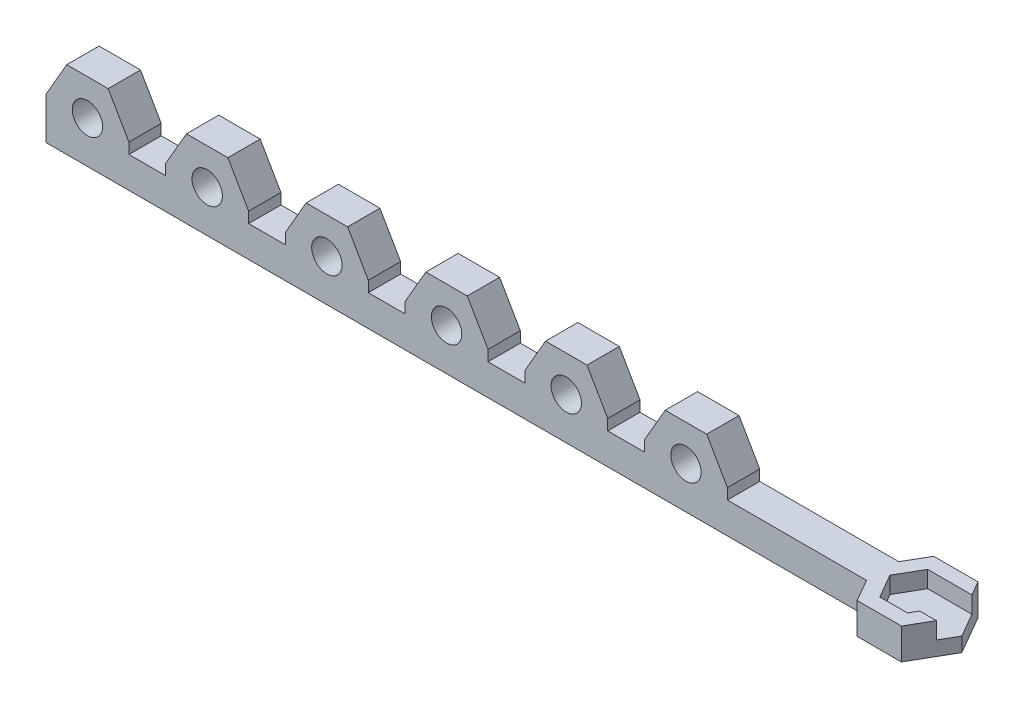
from build123d import *

# Parameters (mm, degrees)
SKETCH1_W           = 175
SKETCH1_H           = 6.75
BOSS_EXTRUDE1_DEPTH = 6.5
SKETCH2_W           = 10
SKETCH2_H           = 6.75
BOSS_EXTRUDE2_DEPTH = 7.5
SKETCH5_R           = 3.175
CUT_EXTRUDE2_DEPTH  = 10
LPATTERN1_COUNT     = 6
LPATTERN1_PITCH     = 25
SKETCH6_R           = 3.175
BOSS_EXTRUDE4_DEPTH = 6.75
LPATTERN2_COUNT     = 6
LPATTERN2_PITCH     = 25
BOSS_EXTRUDE5_DEPTH = 6.5
BOSS_EXTRUDE6_DEPTH = 3
SKETCH10_R          = 2.55
CUT_EXTRUDE4_DEPTH  = 2
CUT_EXTRUDE5_DEPTH  = 18


with BuildPart() as part:
    # Sketch1 → Boss-Extrude1 (new body)
    with BuildSketch(Plane(origin=(0, 0, 0), x_dir=(1, 0, 0), z_dir=(0, 1, 0))):
        with Locations((87.5, -3.375)):
            Rectangle(SKETCH1_W, SKETCH1_H)
    extrude(amount=BOSS_EXTRUDE1_DEPTH)

    # Sketch2 → Boss-Extrude2 (add)
    with BuildSketch(Plane(origin=(0, 6.5, 0), x_dir=(1, 0, 0), z_dir=(0, 1, 0))):
        with Locations((5, -3.375)):
            Rectangle(SKETCH2_W, SKETCH2_H)
    boss_extrude2 = extrude(amount=BOSS_EXTRUDE2_DEPTH)

    # Sketch5 → Cut-Extrude2 (cut)
    with BuildSketch(Plane.XY.offset(6.75)):
        with Locations((5, 8.75)):
            Circle(SKETCH5_R)
    cut_extrude2 = extrude(amount=-CUT_EXTRUDE2_DEPTH, mode=Mode.SUBTRACT)

    # LPattern1: Boss-Extrude2, Cut-Extrude2 ×6
    with Locations(*[(i * LPATTERN1_PITCH, 0, 0) for i in range(1, LPATTERN1_COUNT)]):
        add(boss_extrude2)
        add(cut_extrude2, mode=Mode.SUBTRACT)

    # Sketch6 → Boss-Extrude4 (add)
    with BuildSketch(Plane.XY.offset(6.75)):
        Polygon((138.660254038, 8.75), (138.660254038, 0), (121.339745962, 0), (121.339745962, 8.75), (125.669872981, 16.25), (134.330127019, 16.25), align=None)
        with Locations((130, 8.75)):
            Circle(SKETCH6_R, mode=Mode.SUBTRACT)
    boss_extrude4 = extrude(amount=-BOSS_EXTRUDE4_DEPTH)

    # LPattern2: Boss-Extrude4 ×6
    with Locations(*[(-i * LPATTERN2_PITCH, 0, 0) for i in range(1, LPATTERN2_COUNT)]):
        add(boss_extrude4)

    # Sketch7 → Boss-Extrude5 (add)
    with BuildSketch(Plane(origin=(0, 6.5, 0), x_dir=(1, 0, 0), z_dir=(0, 1, 0))):
        Polygon((172.113248654, -8.375), (177.886751346, -8.375), (178.824945533, -6.75), (182.289047149, -6.75), (179.618802154, -11.375), (170.381197846, -11.375), (165.762395693, -3.375), (170.381197846, 4.625), (179.618802154, 4.625), (181.350852961, 1.625), (177.886751346, 1.625), (172.113248654, 1.625), (169.226497308, -3.375), align=None)
    extrude(amount=-BOSS_EXTRUDE5_DEPTH)

    # Sketch9 → Boss-Extrude6 (add)
    with BuildSketch(Plane(origin=(0, 0, 0), x_dir=(-1, 0, 0), z_dir=(0, -1, 0))):
        Polygon((-169.226497308, -3.375), (-172.113248654, 1.625), (-177.886751346, 1.625), (-181.350852961, 1.625), (-184.237604307, -3.375), (-182.289047149, -6.75), (-178.824945533, -6.75), (-177.886751346, -8.375), (-172.113248654, -8.375), align=None)
    extrude(amount=-BOSS_EXTRUDE6_DEPTH)

    # Sketch10 → Cut-Extrude4 (cut)
    with BuildSketch(Plane(origin=(0, 0, 0), x_dir=(-1, 0, 0), z_dir=(0, -1, 0))):
        with Locations((-175, -3.375)):
            Circle(SKETCH10_R)
    extrude(amount=-CUT_EXTRUDE4_DEPTH, mode=Mode.SUBTRACT)

    # Sketch11 → Cut-Extrude5 (cut)
    with BuildSketch(Plane(origin=(0, 3, 0), x_dir=(1, 0, 0), z_dir=(0, 1, 0))):
        Polygon((180.773502692, -3.375), (177.886751346, 1.625), (172.113248654, 1.625), (169.226497308, -3.375), (172.113248654, -8.375), (177.886751346, -8.375), align=None)
    extrude(amount=CUT_EXTRUDE5_DEPTH, mode=Mode.SUBTRACT)


solid = part.part
